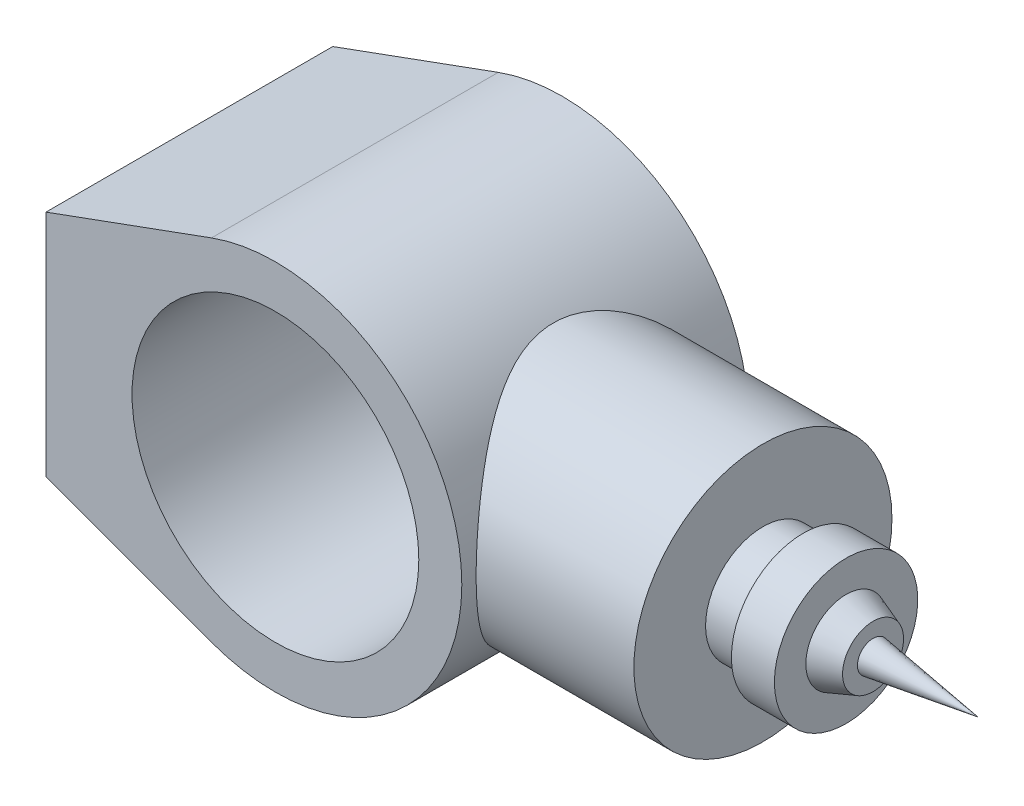
from build123d import *

# Parameters (mm, degrees)
IZIM1_R                     = 50
Y_KSEKLIK_EKSTR_ZYON1_DEPTH = 100
Y_KSEKLIK_EKSTR_ZYON2_REACH = 202
IZIM3_R                     = 45


with BuildPart() as part:
    # Çizim1 → Yükseklik-Ekstrüzyon1 (new body)
    with BuildSketch(Plane.XY):
        with BuildLine():
            Line((-80, -40), (-80, 40))
            Line((-80, 40), (-22.281665693, 61.061668614))
            ThreePointArc((-22.281665693, 61.061668614), (65, 0), (-22.281665693, -61.061668614))
            Line((-22.281665693, -61.061668614), (-80, -40))
        make_face()
        Circle(IZIM1_R, mode=Mode.SUBTRACT)
    extrude(amount=Y_KSEKLIK_EKSTR_ZYON1_DEPTH)

    # Çizim3 → Yükseklik-Ekstrüzyon2 (add, up to next)
    with BuildSketch(Plane(origin=(120, 0, 0), x_dir=(0, 0, -1), z_dir=(1, 0, 0)), mode=Mode.PRIVATE) as y_kseklik_ekstr_zyon2_sk1:
        with Locations((-50, 0)):
            Circle(IZIM3_R)
    y_kseklik_ekstr_zyon2_tool1 = extrude(y_kseklik_ekstr_zyon2_sk1.sketch, amount=-Y_KSEKLIK_EKSTR_ZYON2_REACH, mode=Mode.PRIVATE) - part.part
    add(y_kseklik_ekstr_zyon2_tool1.solids().sort_by_distance((120, 0, 50))[0])

    # Çizim6 → Döndür1 (revolve)
    with BuildSketch(Plane.XY.offset(50)):
        Polygon((120, 0), (120, -20), (134, -20), (134, -25), (149, -25), (149, -14.033097), (158.403875038, -10.632048004), (158.403875038, -5.4519389), (195, 0), align=None)
    revolve(axis=Axis((-133.942981773, 0, 50), (1, 0, 0)))


solid = part.part
